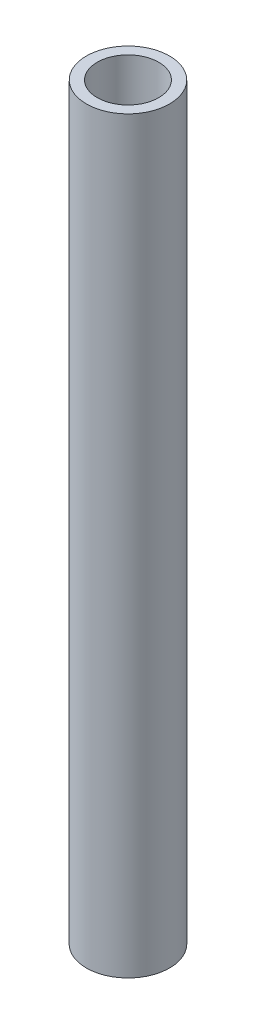
from build123d import *

# Parameters (mm, degrees)
SKETCH1_R                    = 19.05
BOSS_EXTRUDE1_DEPTH          = 342.9
SKETCH2_R                    = 12.7
CUT_EXTRUDE1_DEPTH           = 343.9
F_1_1_4_7_TAPPED_HOLE1_D     = 28.17876
F_1_1_4_7_TAPPED_HOLE1_DEPTH = 49.022
F_1_1_4_7_TAPPED_HOLE1_TIP   = 8.465753589
F_1_1_4_7_TAPPED_HOLE2_D     = 28.17876
F_1_1_4_7_TAPPED_HOLE2_DEPTH = 49.022
F_1_1_4_7_TAPPED_HOLE2_TIP   = 8.465753589


with BuildPart() as part:
    # Sketch1 → Boss-Extrude1 (new body)
    with BuildSketch(Plane(origin=(0, 0, 0), x_dir=(1, 0, 0), z_dir=(0, 1, 0))):
        Circle(SKETCH1_R)
    extrude(amount=BOSS_EXTRUDE1_DEPTH)

    # Sketch2 → Cut-Extrude1 (cut, through all)
    with BuildSketch(Plane(origin=(0, 342.9, 0), x_dir=(1, 0, 0), z_dir=(0, 1, 0))):
        Circle(SKETCH2_R)
    extrude(amount=-CUT_EXTRUDE1_DEPTH, mode=Mode.SUBTRACT)

    # 1-1/4-7 Tapped Hole1
    with Locations(Plane(origin=(0, 342.9, 0), x_dir=(1, 0, 0), z_dir=(0, 1, 0))):
        with Locations((0, 0)):
            Hole(F_1_1_4_7_TAPPED_HOLE1_D / 2, depth=F_1_1_4_7_TAPPED_HOLE1_DEPTH)
            with Locations((0, 0, -(F_1_1_4_7_TAPPED_HOLE1_DEPTH + F_1_1_4_7_TAPPED_HOLE1_TIP / 2))):  # 118° drill point
                Cone(0, F_1_1_4_7_TAPPED_HOLE1_D / 2, F_1_1_4_7_TAPPED_HOLE1_TIP, mode=Mode.SUBTRACT)

    # 1-1/4-7 Tapped Hole2
    with Locations(Plane(origin=(0, 0, 0), x_dir=(-1, 0, 0), z_dir=(0, -1, 0))):
        with Locations((0, 0)):
            Hole(F_1_1_4_7_TAPPED_HOLE2_D / 2, depth=F_1_1_4_7_TAPPED_HOLE2_DEPTH)
            with Locations((0, 0, -(F_1_1_4_7_TAPPED_HOLE2_DEPTH + F_1_1_4_7_TAPPED_HOLE2_TIP / 2))):  # 118° drill point
                Cone(0, F_1_1_4_7_TAPPED_HOLE2_D / 2, F_1_1_4_7_TAPPED_HOLE2_TIP, mode=Mode.SUBTRACT)


solid = part.part
